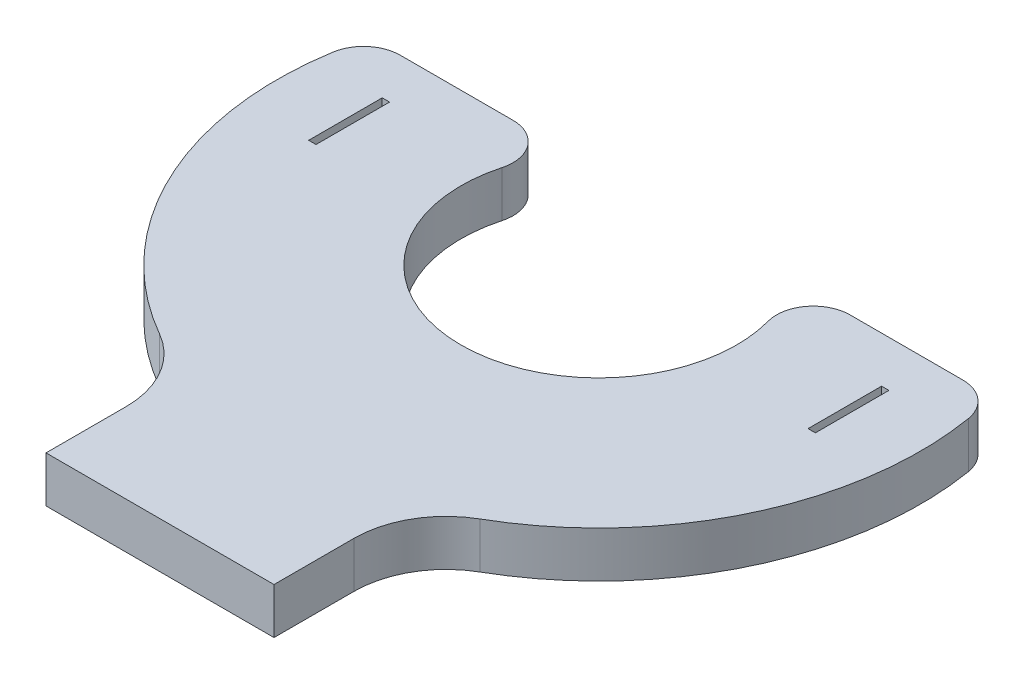
from build123d import *

# Parameters (mm, degrees)
SKETCH1_W           = 0.508
SKETCH1_H           = 5.08
BOSS_EXTRUDE1_DEPTH = 3.175
FILLET1_R           = 2.54
FILLET2_R           = 6.35


with BuildPart() as part:
    # Sketch1 → Boss-Extrude1 (new body)
    with BuildSketch(Plane(origin=(0, 0, 0), x_dir=(1, 0, 0), z_dir=(0, 1, 0))):
        with BuildLine():
            Line((-21.477648847, 5.715), (-7.62, 5.715))
            ThreePointArc((-7.62, 5.715), (0, -9.525), (7.62, 5.715))
            Line((7.62, 5.715), (21.477648847, 5.715))
            ThreePointArc((21.477648847, 5.715), (19.771733676, -10.150328687), (7.874, -20.783424862))
            Line((7.874, -20.783424862), (7.874, -30.308424862))
            Line((7.874, -30.308424862), (-7.874, -30.308424862))
            Line((-7.874, -30.308424862), (-7.874, -20.783424862))
            ThreePointArc((-7.874, -20.783424862), (-19.771733676, -10.150328687), (-21.477648847, 5.715))
        make_face()
        with Locations((-17.2466, 0)):
            Rectangle(SKETCH1_W, SKETCH1_H, mode=Mode.SUBTRACT)
        with Locations((17.2466, 0)):
            Rectangle(SKETCH1_W, SKETCH1_H, mode=Mode.SUBTRACT)
    extrude(amount=BOSS_EXTRUDE1_DEPTH)

    # Fillet1
    fillet1_edges = [part.edges().sort_by_distance(p)[0] for p in [
        (-21.477648847, 1.5875, -5.715),
        (-7.62, 1.5875, -5.715),
        (7.62, 1.5875, -5.715),
        (21.477648847, 1.5875, -5.715),
    ]]
    fillet(fillet1_edges, radius=FILLET1_R)

    # Fillet2
    fillet2_edges = [part.edges().sort_by_distance(p)[0] for p in [
        (7.874, 1.5875, 20.783424862),
        (-7.874, 1.5875, 20.783424862),
    ]]
    fillet(fillet2_edges, radius=FILLET2_R)


solid = part.part
